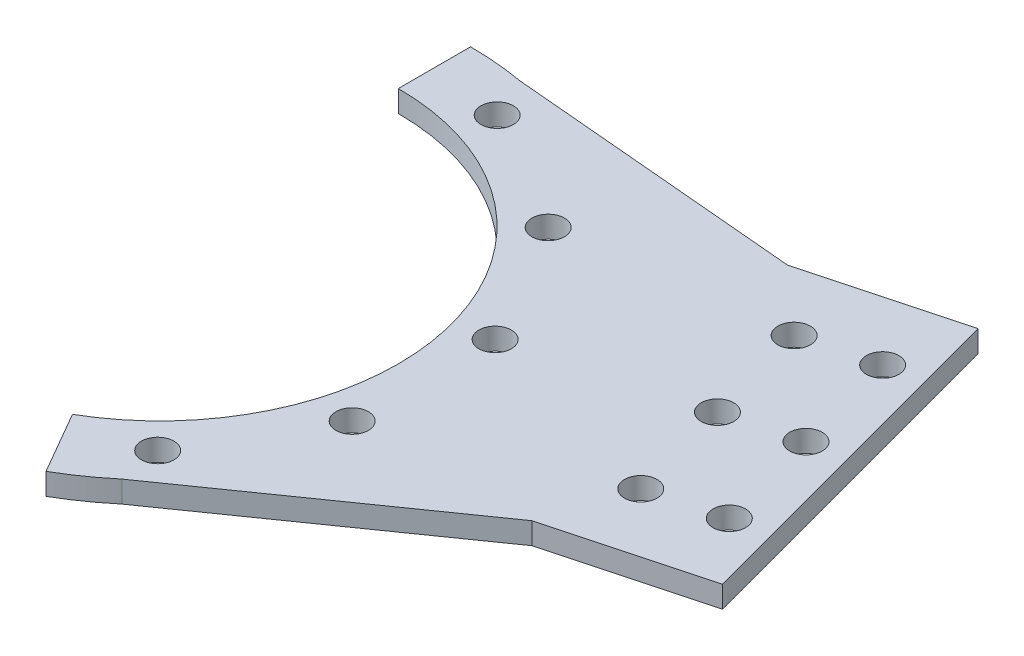
from build123d import *

# Parameters (mm, degrees)
BOSS_EXTRUDE1_DEPTH             = 1.5
BOSS_EXTRUDE2_DEPTH             = 1.5
BOSS_EXTRUDE3_DEPTH             = 1.5
CUT_EXTRUDE1_START              = -4
SKETCH2_R                       = 2.25
CUT_EXTRUDE1_DEPTH              = 5
CIRPATTERN1_COUNT               = 3
CIRPATTERN1_ANGLE               = 60
CIRPATTERN1_THE_OTHER_WAY_COUNT = 3
CIRPATTERN1_THE_OTHER_WAY_ANGLE = 60
CUT_EXTRUDE2_START              = -4
SKETCH6_R                       = 2.25
CUT_EXTRUDE2_DEPTH              = 5
LPATTERN1_COUNT                 = 2
LPATTERN1_PITCH                 = 15
LPATTERN1_COUNT_DIR2            = 2
LPATTERN1_PITCH_DIR2            = 10
LPATTERN2_COUNT                 = 2
LPATTERN2_PITCH                 = 15
LPATTERN2_COUNT_DIR2            = 2
LPATTERN2_PITCH_DIR2            = 10


with BuildPart() as part:
    # Sketch1 → Boss-Extrude1 (new body, symmetric)
    with BuildSketch(Plane(origin=(0, 0, 0), x_dir=(1, 0, 0), z_dir=(0, 1, 0))):
        with BuildLine():
            Line((0, 33), (0, 43))
            ThreePointArc((0, 43), (41.53481053, 11.129218939), (21.5, -37.239092363))
            Line((21.5, -37.239092363), (16.5, -28.578838325))
            ThreePointArc((16.5, -28.578838325), (31.875552268, 8.541028488), (0, 33))
        make_face()
    extrude(amount=BOSS_EXTRUDE1_DEPTH, both=True)

    # Sketch4 → Boss-Extrude2 (add, symmetric)
    with BuildSketch(Plane(origin=(0, 0, 0), x_dir=(1, 0, 0), z_dir=(0, 1, 0))):
        Polygon((68.871738323, 44.336031175), (25.40507614, 32.689174146), (38.346028395, -15.607117169), (81.812690578, -3.960260139), align=None)
    extrude(amount=BOSS_EXTRUDE2_DEPTH, both=True)

    # Sketch5 → Boss-Extrude3 (add, symmetric)
    with BuildSketch(Plane(origin=(0, 0, 0), x_dir=(1, 0, 0), z_dir=(0, 1, 0))):
        Polygon((0, 43), (48.097432179, 38.769572621), (27.323126035, 33.203114066), align=None)
        Polygon((61.038384434, -9.526718694), (40.26407829, -15.093177248), (21.5, -37.239092363), align=None)
    extrude(amount=BOSS_EXTRUDE3_DEPTH, both=True)

    # Sketch2 → Cut-Extrude1 (cut)
    with BuildSketch(Plane(origin=(0, 1.5, 0), x_dir=(1, 0, 0), z_dir=(0, 1, 0)).offset(CUT_EXTRUDE1_START)):
        with Locations((36.757261811, 9.638656763)):
            Circle(SKETCH2_R)
    cut_extrude1 = extrude(amount=CUT_EXTRUDE1_DEPTH, mode=Mode.SUBTRACT)

    # CirPattern1: Cut-Extrude1 ×3 about axis
    cirpattern1_axis = Axis((0, 0, 0), (0, -1, 0))
    for i in range(1, CIRPATTERN1_COUNT):
        add(cut_extrude1.rotate(cirpattern1_axis, i * CIRPATTERN1_ANGLE / (CIRPATTERN1_COUNT - 1)), mode=Mode.SUBTRACT)

    # CirPattern1 the other way: Cut-Extrude1 ×3 about axis
    cirpattern1_the_other_way_axis = Axis((0, 0, 0), (0, 1, 0))
    for i in range(1, CIRPATTERN1_THE_OTHER_WAY_COUNT):
        add(cut_extrude1.rotate(cirpattern1_the_other_way_axis, i * CIRPATTERN1_THE_OTHER_WAY_ANGLE / (CIRPATTERN1_THE_OTHER_WAY_COUNT - 1)), mode=Mode.SUBTRACT)

    # Sketch6 → Cut-Extrude2 (cut)
    with BuildSketch(Plane(origin=(0, 1.5, 0), x_dir=(1, 0, 0), z_dir=(0, 1, 0)).offset(CUT_EXTRUDE2_START)):
        with Locations((70.512585319, 18.893790292)):
            Circle(SKETCH6_R)
    cut_extrude2 = extrude(amount=CUT_EXTRUDE2_DEPTH, mode=Mode.SUBTRACT)

    # LPattern1: Cut-Extrude2 2 × 2
    with Locations(*[Vector(-0.258819045, 0, -0.965925826) * (i * LPATTERN1_PITCH) + Vector(-0.965925826, 0, 0.258819045) * (j * LPATTERN1_PITCH_DIR2) for i in range(LPATTERN1_COUNT) for j in range(LPATTERN1_COUNT_DIR2) if (i, j) != (0, 0)]):
        add(cut_extrude2, mode=Mode.SUBTRACT)

    # LPattern2: Cut-Extrude2 2 × 2
    with Locations(*[Vector(0.258819045, 0, 0.965925826) * (i * LPATTERN2_PITCH) + Vector(-0.965925826, 0, 0.258819045) * (j * LPATTERN2_PITCH_DIR2) for i in range(LPATTERN2_COUNT) for j in range(LPATTERN2_COUNT_DIR2) if (i, j) != (0, 0)]):
        add(cut_extrude2, mode=Mode.SUBTRACT)


solid = part.part
